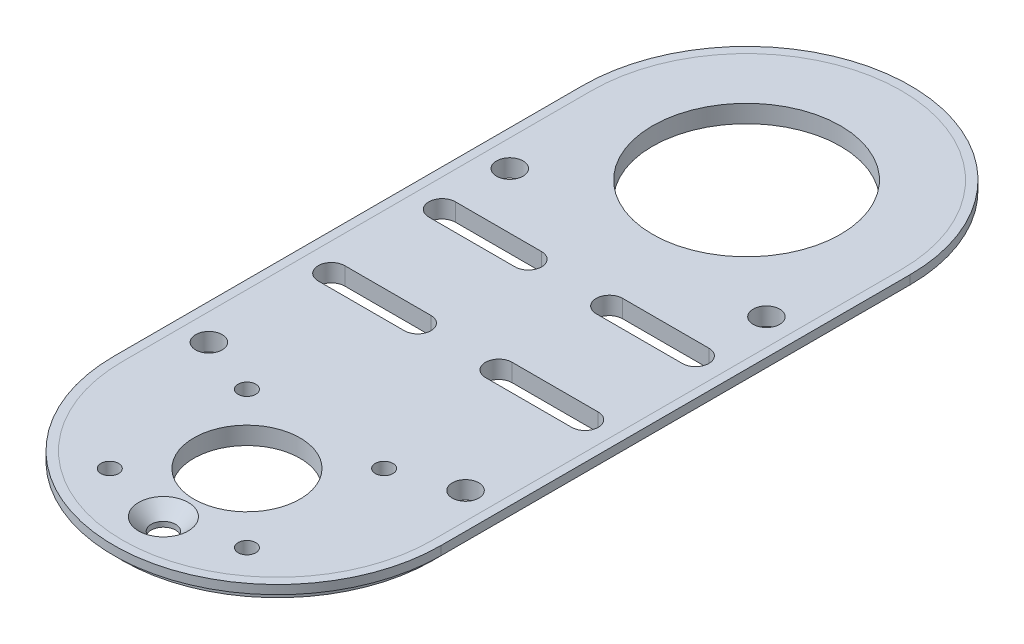
from build123d import *

# Parameters (mm, degrees)
SALIENTE_EXTRUIR1_DEPTH = 4
SALIENTE_EXTRUIR2_DEPTH = 2
CROQUIS4_R              = 3
CROQUIS4_R_2            = 21.25
CROQUIS4_R_3            = 12
CROQUIS4_R_4            = 2
CORTAR_EXTRUIR1_DEPTH   = 10
CORTAR_EXTRUIR2_DEPTH   = 10


with BuildPart() as part:
    # Croquis1 → Saliente-Extruir1 (new body)
    with BuildSketch(Plane(origin=(0, 0, 0), x_dir=(1, 0, 0), z_dir=(0, 1, 0))):
        with BuildLine():
            Line((-35, 88.004281691), (-35, -17.995718309))
            ThreePointArc((-35, -17.995718309), (0, -52.995718309), (35, -17.995718309))
            Line((35, -17.995718309), (35, 88.004281691))
            ThreePointArc((35, 88.004281691), (0, 123.004281691), (-35, 88.004281691))
        make_face()
    extrude(amount=SALIENTE_EXTRUIR1_DEPTH)

    # Croquis4 → Cortar-Extruir1 (cut)
    with BuildSketch(Plane(origin=(0, 4, 0), x_dir=(1, 0, 0), z_dir=(0, 1, 0))):
        with Locations((-29, 63.504281691)):
            Circle(CROQUIS4_R)
        with Locations((-29, -4.495718309)):
            Circle(CROQUIS4_R)
        with Locations((29, -4.495718309)):
            Circle(CROQUIS4_R)
        with Locations((29, 63.504281691)):
            Circle(CROQUIS4_R)
        with Locations((0, 88.004281691)):
            Circle(CROQUIS4_R_2)
        with Locations((0, -24.896258099)):
            Circle(CROQUIS4_R_3)
        with Locations((-15.5, -9.396258099)):
            Circle(CROQUIS4_R_4)
        with Locations((-15.5, -40.396258099)):
            Circle(CROQUIS4_R_4)
        with Locations((15.5, -9.396258099)):
            Circle(CROQUIS4_R_4)
        with Locations((15.5, -40.396258099)):
            Circle(CROQUIS4_R_4)
    extrude(amount=-CORTAR_EXTRUIR1_DEPTH, mode=Mode.SUBTRACT)

    # Croquis10 → Refrentado para tornillo tapón con cabeza plana de clavija de M51 (revolve, cut)
    with BuildSketch(Plane(origin=(0, 4, 43.775718309), x_dir=(0, 0, 1), z_dir=(1, 0, 0))):
        Polygon((0, 0), (0, 4), (2.75, 4), (2.75, 2.85), (5.6, 0), align=None)
    revolve(axis=Axis((0, 10.35, 43.775718309), (0, -1, 0)), mode=Mode.SUBTRACT)

    # Croquis12 → Cortar-Extruir2 (cut)
    with BuildSketch(Plane(origin=(0, 4, 0), x_dir=(1, 0, 0), z_dir=(0, 1, 0))):
        with BuildLine():
            Line((-28.643878295, 25.851786669), (-9.163878295, 25.851786669))
            ThreePointArc((-9.163878295, 25.851786669), (-6.163878295, 22.851786669), (-9.163878295, 19.851786669))
            Line((-9.163878295, 19.851786669), (-28.643878295, 19.851786669))
            ThreePointArc((-28.643878295, 19.851786669), (-31.643878295, 22.851786669), (-28.643878295, 25.851786669))
        make_face()
        with BuildLine():
            Line((-28.643878295, 44.851786669), (-9.163878295, 44.851786669))
            ThreePointArc((-9.163878295, 44.851786669), (-6.163878295, 47.851786669), (-9.163878295, 50.851786669))
            Line((-9.163878295, 50.851786669), (-28.643878295, 50.851786669))
            ThreePointArc((-28.643878295, 50.851786669), (-31.643878295, 47.851786669), (-28.643878295, 44.851786669))
        make_face()
        with BuildLine():
            Line((28.643878295, 25.851786669), (9.163878295, 25.851786669))
            ThreePointArc((9.163878295, 25.851786669), (6.163878295, 22.851786669), (9.163878295, 19.851786669))
            Line((9.163878295, 19.851786669), (28.643878295, 19.851786669))
            ThreePointArc((28.643878295, 19.851786669), (31.643878295, 22.851786669), (28.643878295, 25.851786669))
        make_face()
        with BuildLine():
            Line((28.643878295, 44.851786669), (9.163878295, 44.851786669))
            ThreePointArc((9.163878295, 44.851786669), (6.163878295, 47.851786669), (9.163878295, 50.851786669))
            Line((9.163878295, 50.851786669), (28.643878295, 50.851786669))
            ThreePointArc((28.643878295, 50.851786669), (31.643878295, 47.851786669), (28.643878295, 44.851786669))
        make_face()
    extrude(amount=-CORTAR_EXTRUIR2_DEPTH, mode=Mode.SUBTRACT)


with BuildPart() as body_2:
    # Croquis3 → Saliente-Extruir2 (new body)
    with BuildSketch(Plane(origin=(0, 4, 0), x_dir=(1, 0, 0), z_dir=(0, 1, 0))):
        with BuildLine():
            Line((-37, 88.004281691), (-37, -17.995718309))
            ThreePointArc((-37, -17.995718309), (0, -54.995718309), (37, -17.995718309))
            Line((37, -17.995718309), (37, 88.004281691))
            ThreePointArc((37, 88.004281691), (0, 125.004281691), (-37, 88.004281691))
        make_face()
        with BuildLine():
            Line((-35, 88.004281691), (-35, -17.995718309))
            ThreePointArc((-35, -17.995718309), (0, -52.995718309), (35, -17.995718309))
            Line((35, -17.995718309), (35, 88.004281691))
            ThreePointArc((35, 88.004281691), (0, 123.004281691), (-35, 88.004281691))
        make_face(mode=Mode.SUBTRACT)
    extrude(amount=-SALIENTE_EXTRUIR2_DEPTH)


solid = Compound([part.part, body_2.part])
